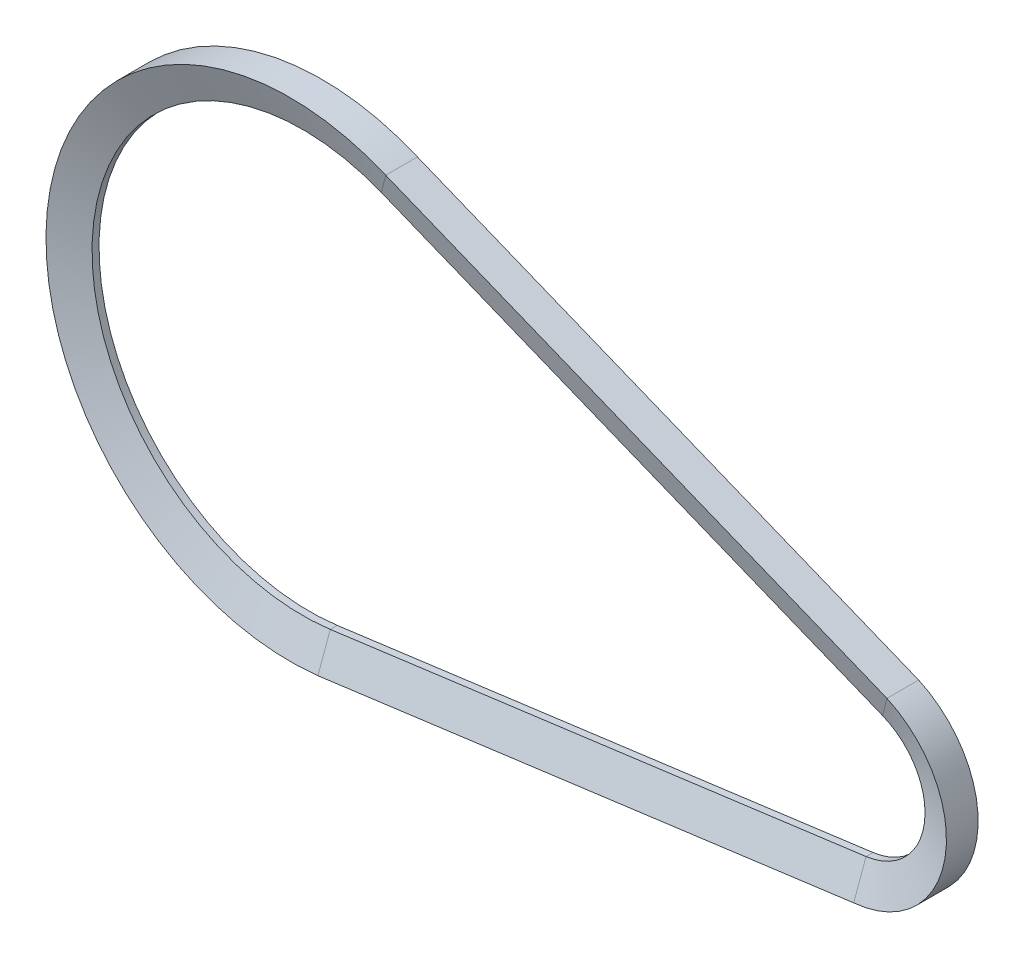
from build123d import *


with BuildPart() as part:
    # Sweep1: sweep along a path in Sketch1
    with BuildLine(Plane.XY) as sweep1_path:
        Line((6.124729851, -46.094876985), (124.475719307, -30.369315156))
        ThreePointArc((124.475719307, -30.369315156), (137.381347861, -17.382946056), (128.117006893, -1.591397138))
        Line((128.117006893, -1.591397138), (17.412721367, 43.116668872))
        ThreePointArc((17.412721367, 43.116668872), (-46.132178368, 5.837132773), (6.124729851, -46.094876985))
    # Sketch2 → Sweep1 (sweep)
    with BuildSketch(Plane(origin=(6.124729851, 0, 0), x_dir=(0, 0, -1), z_dir=(1, 0, 0))):
        Polygon((-0.770223243, -46.094876985), (0.770223243, -46.094876985), (3.5, -53.594876985), (-3.5, -53.594876985), align=None)
    sweep(path=sweep1_path.line)


solid = part.part
